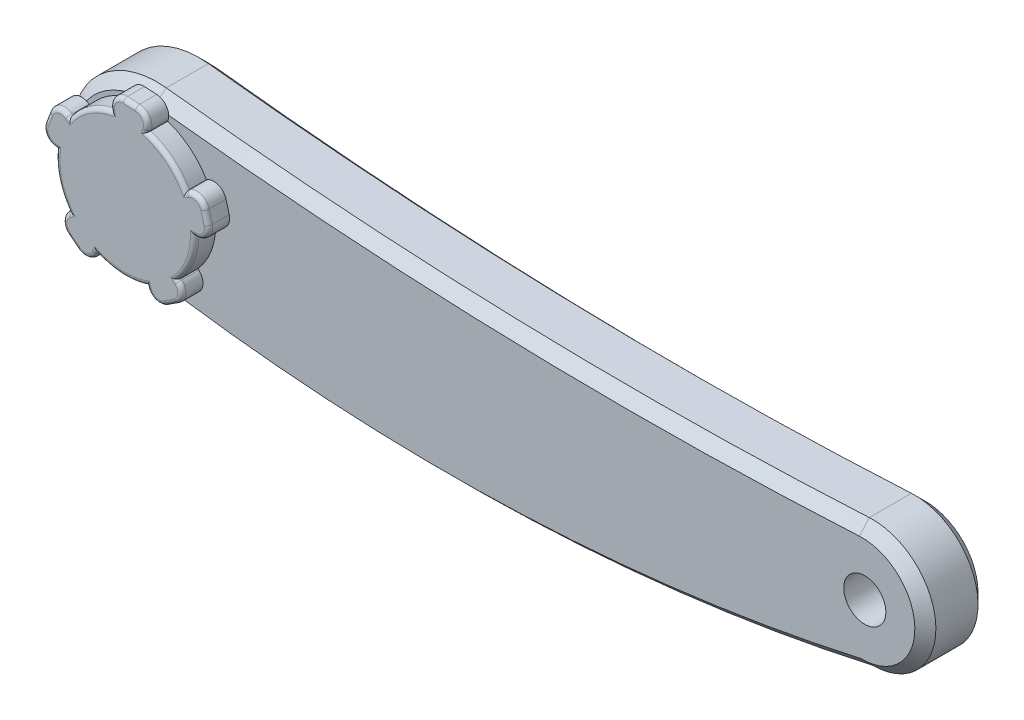
from build123d import *

# Parameters (mm, degrees)
BOSS_EXTRUDE1_DEPTH = 7.5
CHAMFER1_SIZE       = 2.5
SKETCH2_R           = 16.5
BOSS_EXTRUDE2_DEPTH = 5
BOSS_EXTRUDE3_DEPTH = 5
FILLET1_R           = 1
SKETCH4_R           = 5
CUT_EXTRUDE1_DEPTH  = 10
SKETCH5_R           = 5
BOSS_EXTRUDE4_DEPTH = 10


with BuildPart() as part:
    # Sketch1 → Boss-Extrude1 (new body, symmetric)
    with BuildSketch(Plane.XY):
        with BuildLine():
            ThreePointArc((85, -15), (99.994474711, 0.407097217), (84.186105477, 14.977902914))
            ThreePointArc((84.186105477, 14.977902914), (0.617423728, 13.934366249), (-82.746539792, 19.872642429))
            ThreePointArc((-82.746539792, 19.872642429), (-104.804980291, 2.786172224), (-88.316875687, -19.723040731))
            ThreePointArc((-88.316875687, -19.723040731), (-1.428818786, -25.787629696), (85, -15))
        make_face()
    extrude(amount=BOSS_EXTRUDE1_DEPTH, both=True)

    # Chamfer1
    chamfer1_edges = [part.edges().sort_by_distance(p)[0] for p in [
        (99.994474711, 0.407097217, 7.5),
        (0.617423728, 13.934366249, 7.5),
        (-104.804980291, 2.786172224, 7.5),
        (-1.428818786, -25.787629696, 7.5),
        (-104.804980291, 2.786172224, -7.5),
        (0.617423728, 13.934366249, -7.5),
        (99.994474711, 0.407097217, -7.5),
        (-1.428818786, -25.787629696, -7.5),
    ]]
    chamfer(chamfer1_edges, length=CHAMFER1_SIZE)

    # Sketch2 → Boss-Extrude2 (add)
    with BuildSketch(Plane.XY.offset(7.5)):
        with Locations((-85, 0)):
            Circle(SKETCH2_R)
    extrude(amount=BOSS_EXTRUDE2_DEPTH)

    # Sketch3 → Boss-Extrude3 (add)
    with BuildSketch(Plane.XY.offset(12.5)):
        with BuildLine():
            Line((-70.454369396, 8.397923745), (-85, 0))
            Line((-85, 0), (-68.20415251, 0))
            ThreePointArc((-68.20415251, 0), (-65.824092489, 1.173715713), (-65.306375031, 3.776457135))
            Line((-65.306375031, 3.776457135), (-66.056591917, 6.576304669))
            ThreePointArc((-66.056591917, 6.576304669), (-67.806319099, 8.571486131), (-70.454369396, 8.397923745))
        make_face()
        with BuildLine():
            Line((-72.518252849, -11.238615615), (-85, 0))
            Line((-85, 0), (-79.809797691, -15.973800202))
            ThreePointArc((-79.809797691, -15.973800202), (-77.95804872, -17.874673692), (-75.322711037, -17.562760922))
            Line((-75.322711037, -17.562760922), (-72.891727563, -15.984061795))
            ThreePointArc((-72.891727563, -15.984061795), (-71.534892666, -13.703427379), (-72.518252849, -11.238615615))
        make_face()
        with BuildLine():
            Line((-91.831486626, -15.343770181), (-85, 0))
            Line((-85, 0), (-98.588126054, -9.872351454))
            ThreePointArc((-98.588126054, -9.872351454), (-99.823742272, -12.220871592), (-98.71273147, -14.630840322))
            Line((-98.71273147, -14.630840322), (-96.460084172, -16.454998137))
            ThreePointArc((-96.460084172, -16.454998137), (-93.871786907, -17.040670013), (-91.831486626, -15.343770181))
        make_face()
        with BuildLine():
            Line((-101.70383808, 1.755644127), (-85, 0))
            Line((-85, 0), (-98.588126054, 9.872351454))
            ThreePointArc((-98.588126054, 9.872351454), (-101.203527845, 10.321759676), (-103.15222309, 8.52040432))
            Line((-103.15222309, 8.52040432), (-104.190993969, 5.814313662))
            ThreePointArc((-104.190993969, 5.814313662), (-103.948173183, 3.171714119), (-101.70383808, 1.755644127))
        make_face()
        with BuildLine():
            Line((-88.49205305, 16.428817924), (-85, 0))
            Line((-85, 0), (-79.809797691, 15.973800202))
            ThreePointArc((-79.809797691, 15.973800202), (-80.190588674, 18.600069896), (-82.505959371, 19.896739789))
            Line((-82.505959371, 19.896739789), (-85.400602379, 20.048441601))
            ThreePointArc((-85.400602379, 20.048441601), (-87.838828145, 19.000897142), (-88.49205305, 16.428817924))
        make_face()
    extrude(amount=-BOSS_EXTRUDE3_DEPTH)

    # Fillet1
    fillet1_edges = [part.edges().sort_by_distance(p)[0] for p in [
        (-77.95804872, -17.874673692, 12.5),
        (-79.855508642, -15.83311636, 12.5),
        (-74.1072193, -16.773411359, 12.5),
        (-71.534892666, -13.703427379, 12.5),
        (-72.628181614, -11.13963531, 12.5),
        (-85.863543278, -16.477387323, 12.5),
        (-99.823742272, -12.220871592, 12.5),
        (-98.468453231, -9.785404059, 12.5),
        (-97.586407821, -15.542919229, 12.5),
        (-93.871786907, -17.040670013, 12.5),
        (-91.771320618, -15.208635116, 12.5),
        (-100.937776134, -4.270514244, 12.5),
        (-101.203527845, 10.321759676, 12.5),
        (-98.468453231, 9.785404059, 12.5),
        (-103.67160853, 7.167358991, 12.5),
        (-103.948173183, 3.171714119, 12.5),
        (-101.556724677, 1.740181886, 12.5),
        (-93.986544078, 13.838064371, 12.5),
        (-80.190588674, 18.600069896, 12.5),
        (-79.855508642, 15.83311636, 12.5),
        (-83.953280875, 19.972590695, 12.5),
        (-87.838828145, 19.000897142, 12.5),
        (-88.461297974, 16.284126668, 12.5),
        (-74.616213548, 12.822908364, 12.5),
        (-65.824092489, 1.173715713, 12.5),
        (-68.352076255, 0, 12.5),
        (-65.681483474, 5.176380902, 12.5),
        (-67.806319099, 8.571486131, 12.5),
        (-70.582475117, 8.323961872, 12.5),
        (-69.595922963, -5.913071167, 12.5),
    ]]
    fillet(fillet1_edges, radius=FILLET1_R)

    # Sketch4 → Cut-Extrude1 (cut)
    with BuildSketch(Plane.XY.offset(7.5)):
        with Locations((85.615305239, 0)):
            Circle(SKETCH4_R)
    extrude(amount=-CUT_EXTRUDE1_DEPTH, mode=Mode.SUBTRACT)

    # Sketch5 → Boss-Extrude4 (add)
    with BuildSketch(Plane(origin=(0, 0, -7.5), x_dir=(-1, 0, 0), z_dir=(0, 0, -1))):
        with Locations((85, 0)):
            Circle(SKETCH5_R)
    extrude(amount=BOSS_EXTRUDE4_DEPTH)


solid = part.part
